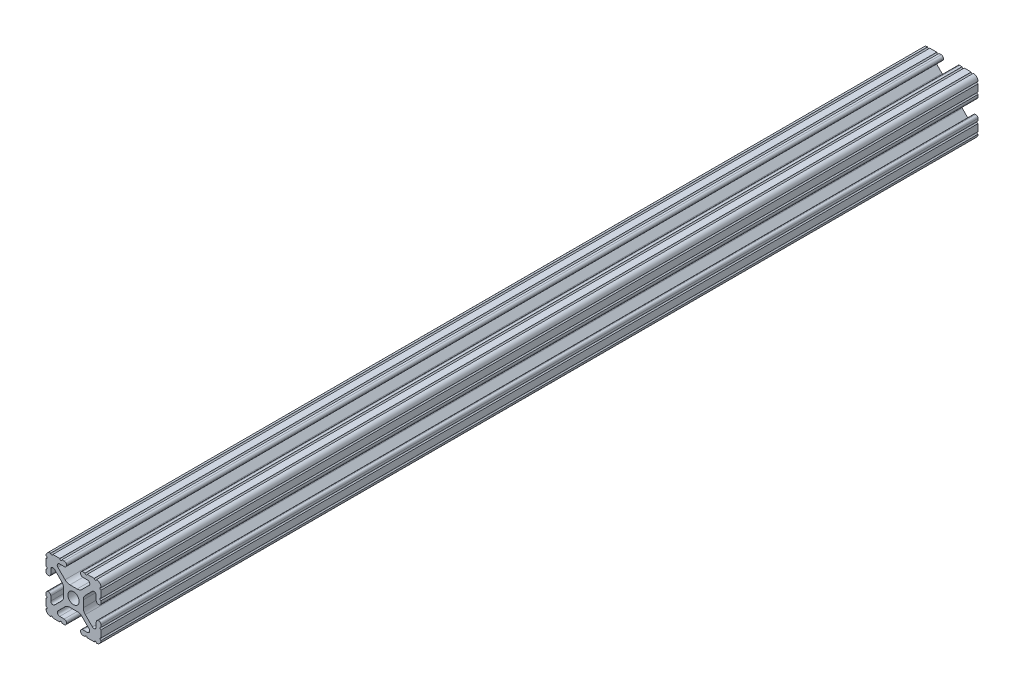
from build123d import *

# Parameters (mm, degrees)
SKETCH1_R      = 2.6035
EXTRUDE1_DEPTH = 404.8125


with BuildPart() as part:
    # Sketch1 → Extrude1 (new body)
    with BuildSketch(Plane.XY):
        with BuildLine():
            Line((-7.207036008, 8.724370562), (-3.898272566, 5.423169045))
            ThreePointArc((-3.898272566, 5.423169045), (-2.869120213, 4.736787962), (-1.655778399, 4.4958))
            Line((-1.655778399, 4.4958), (1.655778399, 4.4958))
            ThreePointArc((1.655778399, 4.4958), (2.869120213, 4.736787962), (3.898272566, 5.423169045))
            Line((3.898272566, 5.423169045), (7.207036008, 8.724370562))
            ThreePointArc((7.207036008, 8.724370562), (7.432222385, 9.85140422), (6.476788598, 10.4902))
            Line((6.476788598, 10.4902), (4.287512407, 10.4902))
            ThreePointArc((4.287512407, 10.4902), (3.54574862, 10.79744862), (3.2385, 11.539212407))
            Line((3.2385, 11.539212407), (3.2385, 11.650987593))
            ThreePointArc((3.2385, 11.650987593), (3.54574862, 12.39275138), (4.287512407, 12.7))
            Line((4.287512407, 12.7), (5.317126718, 12.7))
            ThreePointArc((5.317126718, 12.7), (5.825126718, 12.192), (6.333126718, 12.7))
            Line((6.333126718, 12.7), (9.550443118, 12.7))
            ThreePointArc((9.550443118, 12.7), (10.058366869, 12.192000006), (10.566443095, 12.699847501))
            ThreePointArc((10.566443095, 12.699847501), (12.082537762, 12.08250727), (12.699846982, 10.566399977))
            ThreePointArc((12.699846982, 10.566399977), (12.192000006, 10.058323491), (12.7, 9.5504))
            Line((12.7, 9.5504), (12.7, 6.3330836))
            ThreePointArc((12.7, 6.3330836), (12.192, 5.8250836), (12.7, 5.3170836))
            Line((12.7, 5.3170836), (12.7, 4.287469289))
            ThreePointArc((12.7, 4.287469289), (12.39275138, 3.545705502), (11.650987593, 3.238456882))
            Line((11.650987593, 3.238456882), (11.539212407, 3.238456882))
            ThreePointArc((11.539212407, 3.238456882), (10.79744862, 3.545705502), (10.4902, 4.287469289))
            Line((10.4902, 4.287469289), (10.4902, 6.402089023))
            ThreePointArc((10.4902, 6.402089023), (9.856505071, 7.351067942), (8.737131347, 7.129408934))
            Line((8.737131347, 7.129408934), (5.441005833, 3.840816462))
            ThreePointArc((5.441005833, 3.840816462), (4.750877967, 2.809883091), (4.5085, 1.593185507))
            Line((4.5085, 1.593185507), (4.5085, -1.593185507))
            ThreePointArc((4.5085, -1.593185507), (4.750877967, -2.809883091), (5.441005833, -3.840816462))
            Line((5.441005833, -3.840816462), (8.737131347, -7.129408934))
            ThreePointArc((8.737131347, -7.129408934), (9.856505071, -7.351067942), (10.4902, -6.402089023))
            Line((10.4902, -6.402089023), (10.4902, -4.287469289))
            ThreePointArc((10.4902, -4.287469289), (10.79744862, -3.545705502), (11.539212407, -3.238456882))
            Line((11.539212407, -3.238456882), (11.650987593, -3.238456882))
            ThreePointArc((11.650987593, -3.238456882), (12.39275138, -3.545705502), (12.7, -4.287469289))
            Line((12.7, -4.287469289), (12.7, -5.3170836))
            ThreePointArc((12.7, -5.3170836), (12.192, -5.8250836), (12.7, -6.3330836))
            Line((12.7, -6.3330836), (12.7, -9.5504))
            ThreePointArc((12.7, -9.5504), (12.192000006, -10.058323491), (12.699846982, -10.566399977))
            ThreePointArc((12.699846982, -10.566399977), (12.082537762, -12.08250727), (10.566443095, -12.699847501))
            ThreePointArc((10.566443095, -12.699847501), (10.058366869, -12.192000006), (9.550443118, -12.7))
            Line((9.550443118, -12.7), (6.333126718, -12.7))
            ThreePointArc((6.333126718, -12.7), (5.825126718, -12.192), (5.317126718, -12.7))
            Line((5.317126718, -12.7), (4.287512407, -12.7))
            ThreePointArc((4.287512407, -12.7), (3.54574862, -12.39275138), (3.2385, -11.650987593))
            Line((3.2385, -11.650987593), (3.2385, -11.539212407))
            ThreePointArc((3.2385, -11.539212407), (3.54574862, -10.79744862), (4.287512407, -10.4902))
            Line((4.287512407, -10.4902), (6.416408329, -10.4902))
            ThreePointArc((6.416408329, -10.4902), (7.41473083, -9.822813117), (7.179650497, -8.645192506))
            Line((7.179650497, -8.645192506), (3.952270251, -5.423690499))
            ThreePointArc((3.952270251, -5.423690499), (2.922936451, -4.736929036), (1.709253557, -4.4958))
            Line((1.709253557, -4.4958), (-1.709253557, -4.4958))
            ThreePointArc((-1.709253557, -4.4958), (-2.922936451, -4.736929036), (-3.952270251, -5.423690499))
            Line((-3.952270251, -5.423690499), (-7.179650497, -8.645192506))
            ThreePointArc((-7.179650497, -8.645192506), (-7.41473083, -9.822813117), (-6.416408329, -10.4902))
            Line((-6.416408329, -10.4902), (-4.287512407, -10.4902))
            ThreePointArc((-4.287512407, -10.4902), (-3.54574862, -10.79744862), (-3.2385, -11.539212407))
            Line((-3.2385, -11.539212407), (-3.2385, -11.650987593))
            ThreePointArc((-3.2385, -11.650987593), (-3.54574862, -12.39275138), (-4.287512407, -12.7))
            Line((-4.287512407, -12.7), (-5.317126718, -12.7))
            ThreePointArc((-5.317126718, -12.7), (-5.825126718, -12.192), (-6.333126718, -12.7))
            Line((-6.333126718, -12.7), (-9.550443118, -12.7))
            ThreePointArc((-9.550443118, -12.7), (-10.058366869, -12.192000006), (-10.566443095, -12.699847501))
            ThreePointArc((-10.566443095, -12.699847501), (-12.082537762, -12.08250727), (-12.699846982, -10.566399977))
            ThreePointArc((-12.699846982, -10.566399977), (-12.192000006, -10.058323491), (-12.7, -9.5504))
            Line((-12.7, -9.5504), (-12.7, -6.3330836))
            ThreePointArc((-12.7, -6.3330836), (-12.192, -5.8250836), (-12.7, -5.3170836))
            Line((-12.7, -5.3170836), (-12.7, -4.287469289))
            ThreePointArc((-12.7, -4.287469289), (-12.39275138, -3.545705502), (-11.650987593, -3.238456882))
            Line((-11.650987593, -3.238456882), (-11.539212407, -3.238456882))
            ThreePointArc((-11.539212407, -3.238456882), (-10.79744862, -3.545705502), (-10.4902, -4.287469289))
            Line((-10.4902, -4.287469289), (-10.4902, -6.402089023))
            ThreePointArc((-10.4902, -6.402089023), (-9.856505071, -7.351067942), (-8.737131347, -7.129408934))
            Line((-8.737131347, -7.129408934), (-5.441005833, -3.840816462))
            ThreePointArc((-5.441005833, -3.840816462), (-4.750877967, -2.809883091), (-4.5085, -1.593185507))
            Line((-4.5085, -1.593185507), (-4.5085, 1.593185507))
            ThreePointArc((-4.5085, 1.593185507), (-4.750877967, 2.809883091), (-5.441005833, 3.840816462))
            Line((-5.441005833, 3.840816462), (-8.737131347, 7.129408934))
            ThreePointArc((-8.737131347, 7.129408934), (-9.856505071, 7.351067942), (-10.4902, 6.402089023))
            Line((-10.4902, 6.402089023), (-10.4902, 4.287469289))
            ThreePointArc((-10.4902, 4.287469289), (-10.79744862, 3.545705502), (-11.539212407, 3.238456882))
            Line((-11.539212407, 3.238456882), (-11.650987593, 3.238456882))
            ThreePointArc((-11.650987593, 3.238456882), (-12.39275138, 3.545705502), (-12.7, 4.287469289))
            Line((-12.7, 4.287469289), (-12.7, 5.3170836))
            ThreePointArc((-12.7, 5.3170836), (-12.192, 5.8250836), (-12.7, 6.3330836))
            Line((-12.7, 6.3330836), (-12.7, 9.5504))
            ThreePointArc((-12.7, 9.5504), (-12.192000006, 10.058323491), (-12.699846982, 10.566399977))
            ThreePointArc((-12.699846982, 10.566399977), (-12.082537762, 12.08250727), (-10.566443095, 12.699847501))
            ThreePointArc((-10.566443095, 12.699847501), (-10.058366869, 12.192000006), (-9.550443118, 12.7))
            Line((-9.550443118, 12.7), (-6.333126718, 12.7))
            ThreePointArc((-6.333126718, 12.7), (-5.825126718, 12.192), (-5.317126718, 12.7))
            Line((-5.317126718, 12.7), (-4.287512407, 12.7))
            ThreePointArc((-4.287512407, 12.7), (-3.54574862, 12.39275138), (-3.2385, 11.650987593))
            Line((-3.2385, 11.650987593), (-3.2385, 11.539212407))
            ThreePointArc((-3.2385, 11.539212407), (-3.54574862, 10.79744862), (-4.287512407, 10.4902))
            Line((-4.287512407, 10.4902), (-6.476788598, 10.4902))
            ThreePointArc((-6.476788598, 10.4902), (-7.432222385, 9.85140422), (-7.207036008, 8.724370562))
        make_face()
        Circle(SKETCH1_R, mode=Mode.SUBTRACT)
    extrude(amount=-EXTRUDE1_DEPTH)


solid = part.part
